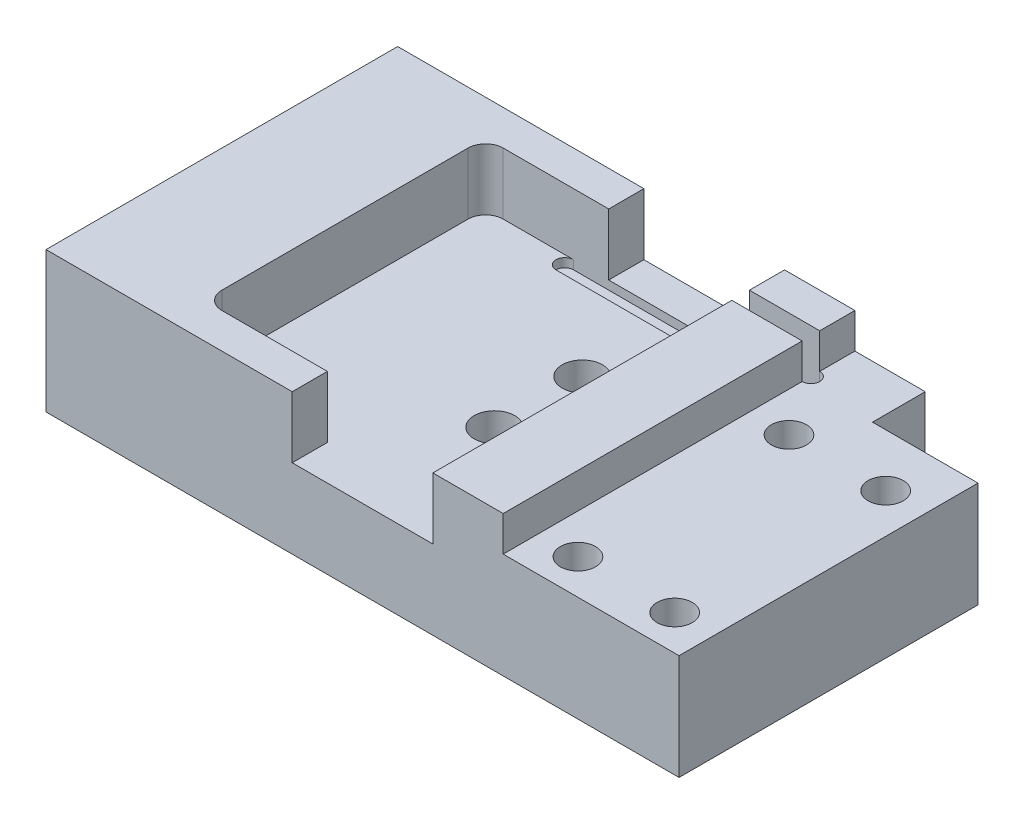
from build123d import *

# Parameters (mm, degrees)
SKETCH_1_W           = 36
SKETCH_1_H           = 20
EXTRUDE_1_DEPTH      = 8
SKETCH_2_W           = 8
SKETCH_2_H           = 20
CUT_EXTRUDE_1_DEPTH  = 3.5
SKETCH_3_R           = 2.5
CUT_EXTRUDE_2_DEPTH  = 4
SKETCH_5_W           = 7
SKETCH_5_H           = 16
CUT_EXTRUDE_4_DEPTH  = 3.5
FILLET_1_R           = 1
SKETCH_6_R           = 1.15
CUT_EXTRUDE_5_DEPTH  = 5.5
SKETCH_7_W           = 10
SKETCH_7_H           = 20
CUT_EXTRUDE_6_DEPTH  = 2
CUT_EXTRUDE_7_DEPTH  = 4
SKETCH_9_R           = 1
CUT_EXTRUDE_10_DEPTH = 3
SKETCH_10_R          = 2
CUT_EXTRUDE_11_DEPTH = 2.4
SKETCH_11_W          = 6
SKETCH_11_H          = 6
CUT_EXTRUDE_15_DEPTH = 3


with BuildPart() as part:
    # 草图1 → 凸台-拉伸1 (new body)
    with BuildSketch(Plane(origin=(0, 0, 0), x_dir=(1, 0, 0), z_dir=(0, 1, 0))):
        with Locations((-18, 10)):
            Rectangle(SKETCH_1_W, SKETCH_1_H)
    extrude(amount=EXTRUDE_1_DEPTH)

    # 草图2 → 切除-拉伸1 (cut)
    with BuildSketch(Plane(origin=(0, 8, 0), x_dir=(1, 0, 0), z_dir=(0, 1, 0))):
        with Locations((-18, 10)):
            Rectangle(SKETCH_2_W, SKETCH_2_H)
    extrude(amount=-CUT_EXTRUDE_1_DEPTH, mode=Mode.SUBTRACT)

    # 草图3 → 切除-拉伸2 (cut)
    with BuildSketch(Plane(origin=(0, 0, 0), x_dir=(-1, 0, 0), z_dir=(0, -1, 0))):
        with Locations((8, 10)):
            Circle(SKETCH_3_R)
        with Locations((28, 10)):
            Circle(SKETCH_3_R)
    extrude(amount=-CUT_EXTRUDE_2_DEPTH, mode=Mode.SUBTRACT)

    # 草图5 → 切除-拉伸4 (cut)
    with BuildSketch(Plane(origin=(0, 8, 0), x_dir=(1, 0, 0), z_dir=(0, 1, 0))):
        with Locations((-25.5, 10)):
            Rectangle(SKETCH_5_W, SKETCH_5_H)
    extrude(amount=-CUT_EXTRUDE_4_DEPTH, mode=Mode.SUBTRACT)

    # 圆角1
    fillet_1_edges = [part.edges().sort_by_distance(p)[0] for p in [
        (-29, 6.25, -2),
        (-29, 6.25, -18),
    ]]
    fillet(fillet_1_edges, radius=FILLET_1_R)

    # 草图6 → 切除-拉伸5 (cut, through all)
    with BuildSketch(Plane(origin=(0, 4.5, 0), x_dir=(1, 0, 0), z_dir=(0, 1, 0))):
        with Locations((-18, 12.5)):
            Circle(SKETCH_6_R)
        with Locations((-18, 7.5)):
            Circle(SKETCH_6_R)
    extrude(amount=-CUT_EXTRUDE_5_DEPTH, mode=Mode.SUBTRACT)

    # 草图7 → 切除-拉伸6 (cut)
    with BuildSketch(Plane(origin=(0, 8, 0), x_dir=(1, 0, 0), z_dir=(0, 1, 0))):
        with Locations((-5, 10)):
            Rectangle(SKETCH_7_W, SKETCH_7_H)
    extrude(amount=-CUT_EXTRUDE_6_DEPTH, mode=Mode.SUBTRACT)

    # 草图8 → 切除-拉伸7 (cut)
    with BuildSketch(Plane(origin=(0, 8, 0), x_dir=(1, 0, 0), z_dir=(0, 1, 0))):
        with BuildLine():
            Line((-24, 18), (-10, 18))
            ThreePointArc((-10, 18), (-9.5, 17.5), (-10, 17))
            Line((-10, 17), (-24, 17))
            ThreePointArc((-24, 17), (-24.5, 17.5), (-24, 18))
        make_face()
    extrude(amount=-CUT_EXTRUDE_7_DEPTH, mode=Mode.SUBTRACT)

    # 草图9 → 切除-拉伸10 (cut)
    with BuildSketch(Plane(origin=(0, 6, 0), x_dir=(1, 0, 0), z_dir=(0, 1, 0))):
        with Locations((-2.25, 2)):
            Circle(SKETCH_9_R)
        with Locations((-7.75, 2)):
            Circle(SKETCH_9_R)
        with Locations((-2.25, 14)):
            Circle(SKETCH_9_R)
        with Locations((-7.75, 14)):
            Circle(SKETCH_9_R)
    extrude(amount=-CUT_EXTRUDE_10_DEPTH, mode=Mode.SUBTRACT)

    # 草图10 → 切除-拉伸11 (cut)
    with BuildSketch(Plane(origin=(0, 0, 0), x_dir=(-1, 0, 0), z_dir=(0, -1, 0))):
        with Locations((18, 12.5)):
            Circle(SKETCH_10_R)
        with Locations((18, 7.5)):
            Circle(SKETCH_10_R)
    extrude(amount=-CUT_EXTRUDE_11_DEPTH, mode=Mode.SUBTRACT)

    # 草图11 → 切除-拉伸15 (cut)
    with BuildSketch(Plane(origin=(0, 0, -20), x_dir=(-1, 0, 0), z_dir=(0, 0, -1))):
        with Locations((3, 3)):
            Rectangle(SKETCH_11_W, SKETCH_11_H)
        with Locations((33, 3)):
            Rectangle(SKETCH_11_W, SKETCH_11_H)
    extrude(amount=-CUT_EXTRUDE_15_DEPTH, mode=Mode.SUBTRACT)


solid = part.part
